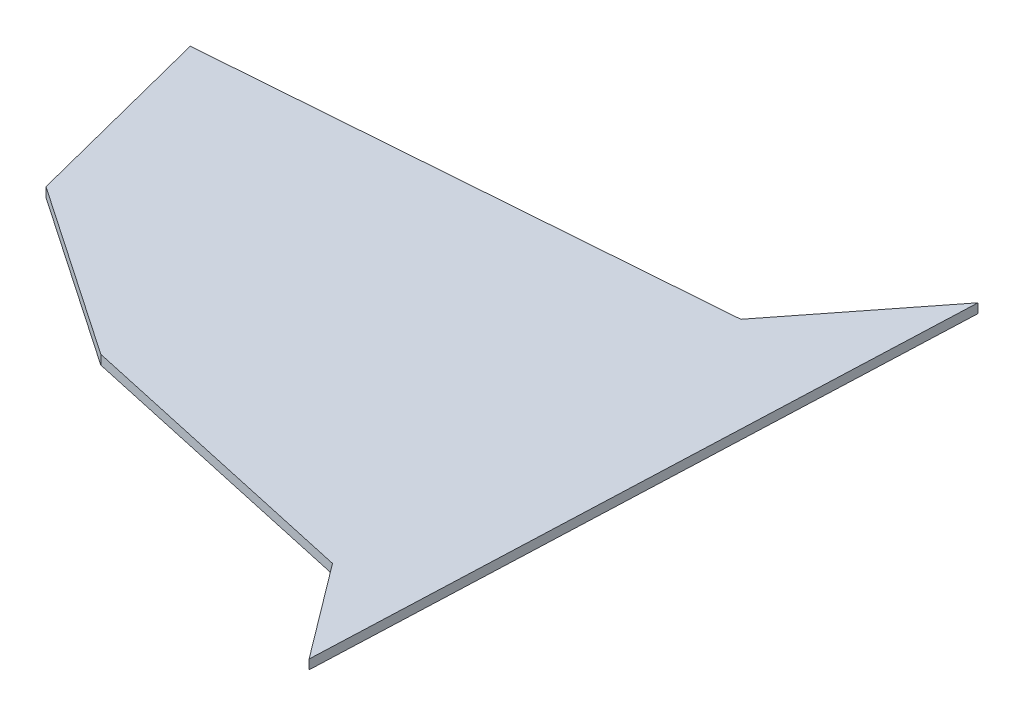
from build123d import *

# Parameters (mm, degrees)
BOSS_EXTRU_1_DEPTH = 2


with BuildPart() as part:
    # Esquisse2 → Boss.-Extru.1 (new body)
    with BuildSketch(Plane(origin=(0, 0, 0), x_dir=(1, 0, 0), z_dir=(0, 1, 0))):
        Polygon((120.737356273, 77.890345785), (98.511155938, 49.572631154), (-10.566655032, 41.307698939), (0, 0), (36.764174615, -25.087516833), (100.061690001, -38.997659914), (115.20474249, -59.133372902), align=None)
    extrude(amount=BOSS_EXTRU_1_DEPTH)


solid = part.part
